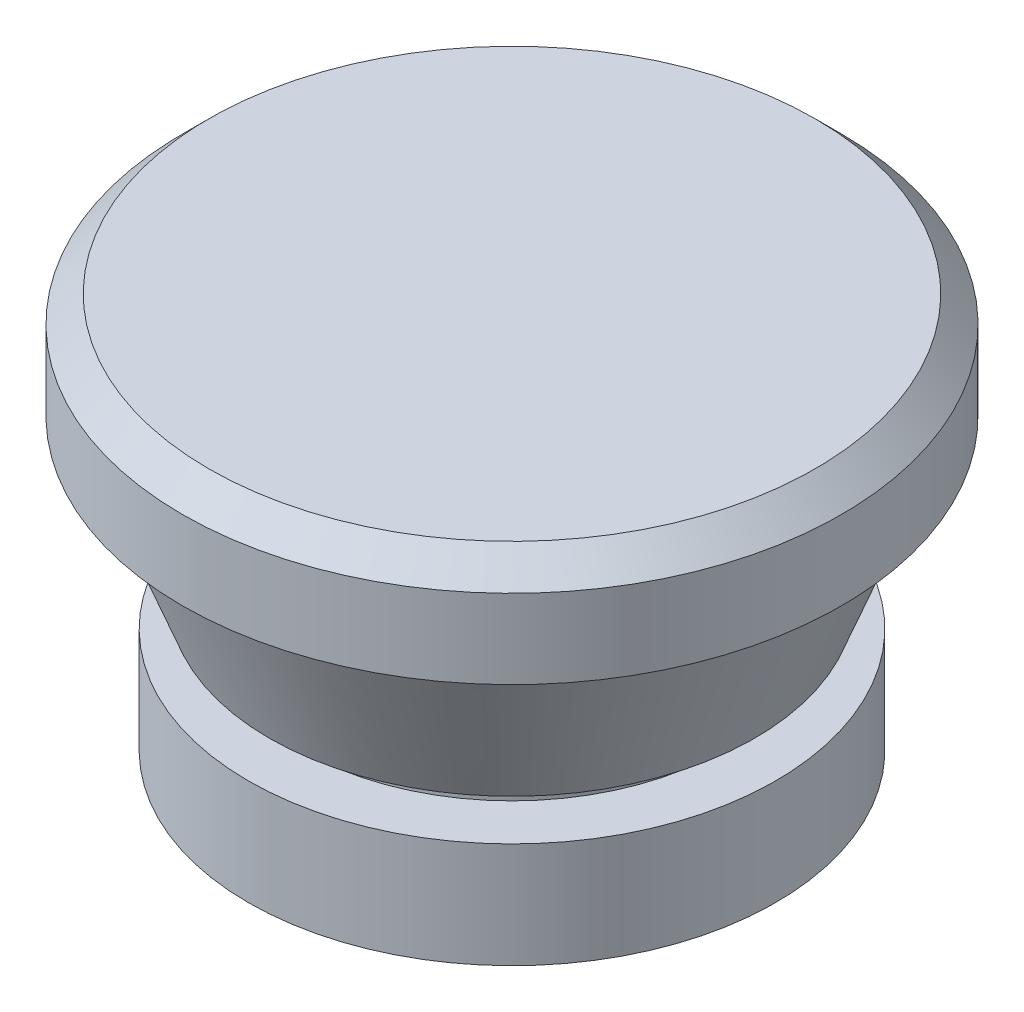
from build123d import *

# Parameters (mm, degrees)
SKETCH3_R          = 5.5
CUT_EXTRUDE1_DEPTH = 3


with BuildPart() as part:
    # Sketch2 → Revolve1 (revolve)
    with BuildSketch(Plane.XY):
        Polygon((0, 0), (0, 15), (11.5, 15), (12.5, 14), (12.5, 11), (11.5, 11), (9.202672606, 5), (8, 5), (8, 4), (10, 4), (10, 0), align=None)
    revolve(axis=Axis((0, 15.75, 0), (0, -1, 0)))

    # Sketch3 → Cut-Extrude1 (cut)
    with BuildSketch(Plane.XZ):
        Circle(SKETCH3_R)
    extrude(amount=-CUT_EXTRUDE1_DEPTH, mode=Mode.SUBTRACT)


solid = part.part
